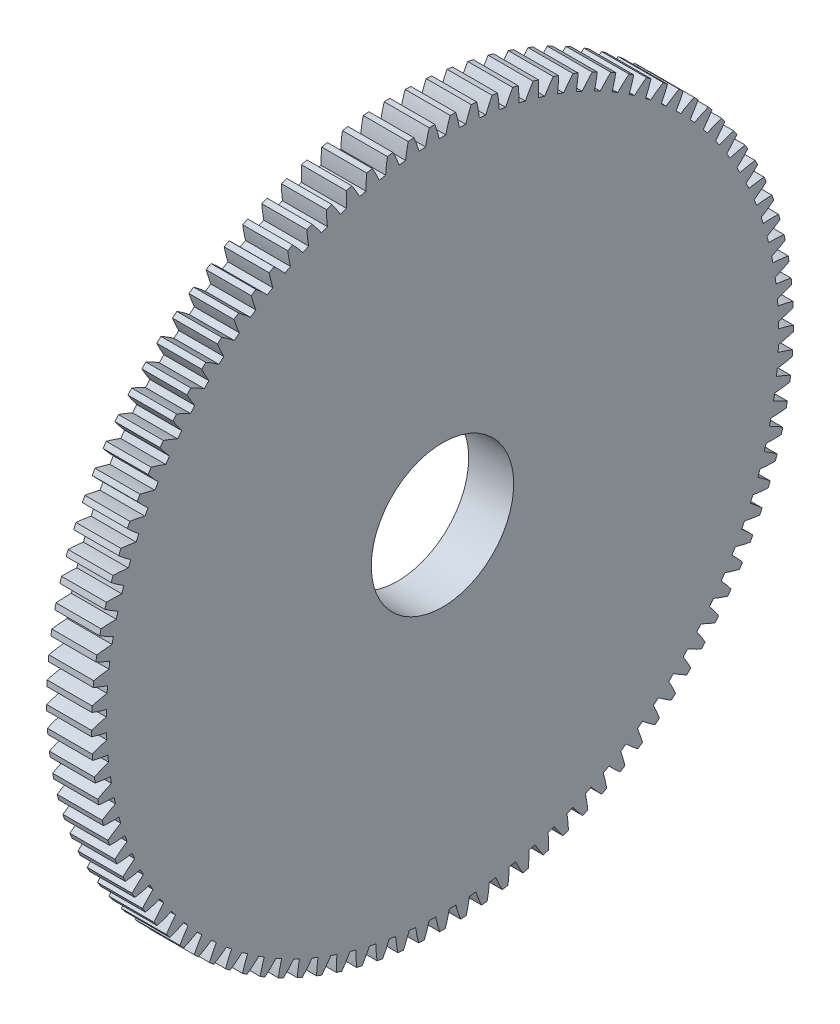
from build123d import *

# Parameters (mm, degrees)
BASPROSKE_W     = 12
BASPROSKE_H     = 93.625
TOOTHCUT_DEPTH  = 133.948415748
TEETHCUTS_COUNT = 105
TEETHCUTS_ANGLE = 356.571428571
BORSKE_R        = 19
BORE_DEPTH      = 50.0000508


with BuildPart() as part:
    # BasProSke → Base-Revolve (revolve)
    with BuildSketch(Plane(origin=(0, 0, 0), x_dir=(1, 0, 0), z_dir=(0, 1, 0)), mode=Mode.PRIVATE) as base_revolve_sk:
        with Locations((6, 46.8125)):
            Rectangle(BASPROSKE_W, BASPROSKE_H)
    revolve(base_revolve_sk.sketch.rotate(Axis((-10, 0, 0), (1, 0, 0)), 180), axis=Axis((-10, 0, 0), (1, 0, 0)))

    # TooCutSke → ToothCut (cut, through all)
    with BuildSketch(Plane(origin=(0, 0, 0), x_dir=(0, 0, -1), z_dir=(1, 0, 0))):
        with BuildLine():
            ThreePointArc((0.86989739, 89.682281197), (0, 89.6865), (-0.86989739, 89.682281197))
            ThreePointArc((-0.86989739, 89.682281197), (-1.408857954, 91.671699751), (-2.058503954, 93.627773559))
            ThreePointArc((-2.058503954, 93.627773559), (0, 93.6504), (2.058503954, 93.627773559))
            ThreePointArc((2.058503954, 93.627773559), (1.408857954, 91.671699751), (0.86989739, 89.682281197))
        make_face()
    toothcut = extrude(amount=TOOTHCUT_DEPTH, mode=Mode.SUBTRACT)

    # TeethCuts: ToothCut ×105 about axis
    teethcuts_axis = Axis((-10, 0, 0), (1, 0, 0))
    for i in range(1, TEETHCUTS_COUNT):
        add(toothcut.rotate(teethcuts_axis, i * TEETHCUTS_ANGLE / (TEETHCUTS_COUNT - 1)), mode=Mode.SUBTRACT)

    # BorSke → Bore (cut, symmetric)
    with BuildSketch(Plane(origin=(0, 0, 0), x_dir=(0, 0, -1), z_dir=(1, 0, 0))):
        with Locations(Location((0, 0, 0), (0, 0, 180))):
            Circle(BORSKE_R)
    extrude(amount=BORE_DEPTH, both=True, mode=Mode.SUBTRACT)


solid = part.part
